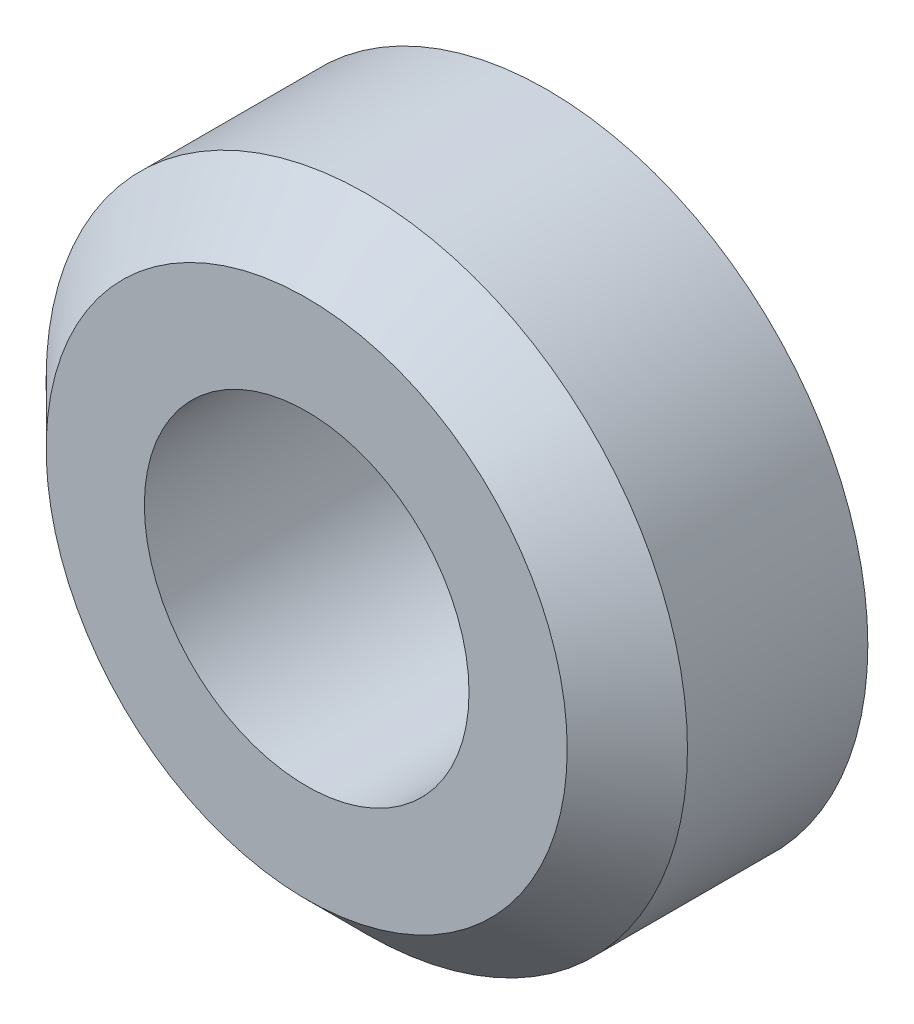
from build123d import *

# Parameters (mm, degrees)
SCHIZZO1_R                   = 8
SCHIZZO1_R_2                 = 4.05
ESTRUSIONE_ESTRUSIONE1_DEPTH = 6
SMUSSO1_SIZE                 = 1.5


with BuildPart() as part:
    # Schizzo1 → Estrusione-Estrusione1 (new body)
    with BuildSketch(Plane.XY):
        Circle(SCHIZZO1_R)
        Circle(SCHIZZO1_R_2, mode=Mode.SUBTRACT)
    extrude(amount=ESTRUSIONE_ESTRUSIONE1_DEPTH)

    # Smusso1
    smusso1_edges = [part.edges().sort_by_distance(p)[0] for p in [
        (-8, 0, 6),
    ]]
    chamfer(smusso1_edges, length=SMUSSO1_SIZE)


solid = part.part
